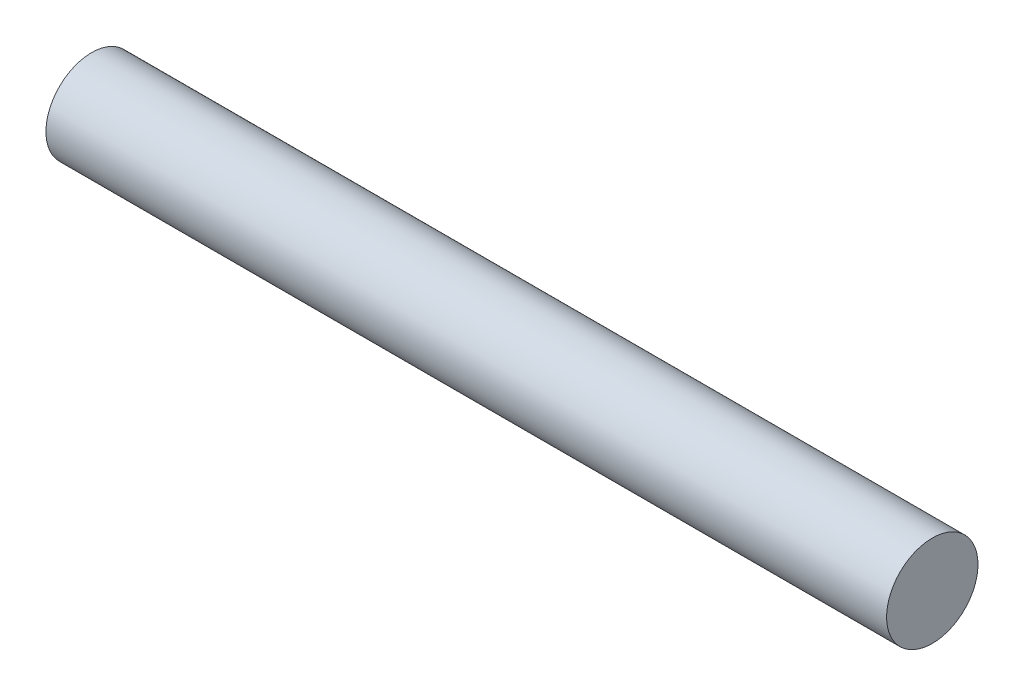
from build123d import *

# Parameters (mm, degrees)
SKETCH1_R           = 1.25
BOSS_EXTRUDE1_DEPTH = 23


with BuildPart() as part:
    # Sketch1 → Boss-Extrude1 (new body)
    with BuildSketch(Plane(origin=(0, 0, 0), x_dir=(0, 0, -1), z_dir=(1, 0, 0))):
        Circle(SKETCH1_R)
    extrude(amount=BOSS_EXTRUDE1_DEPTH)


solid = part.part
